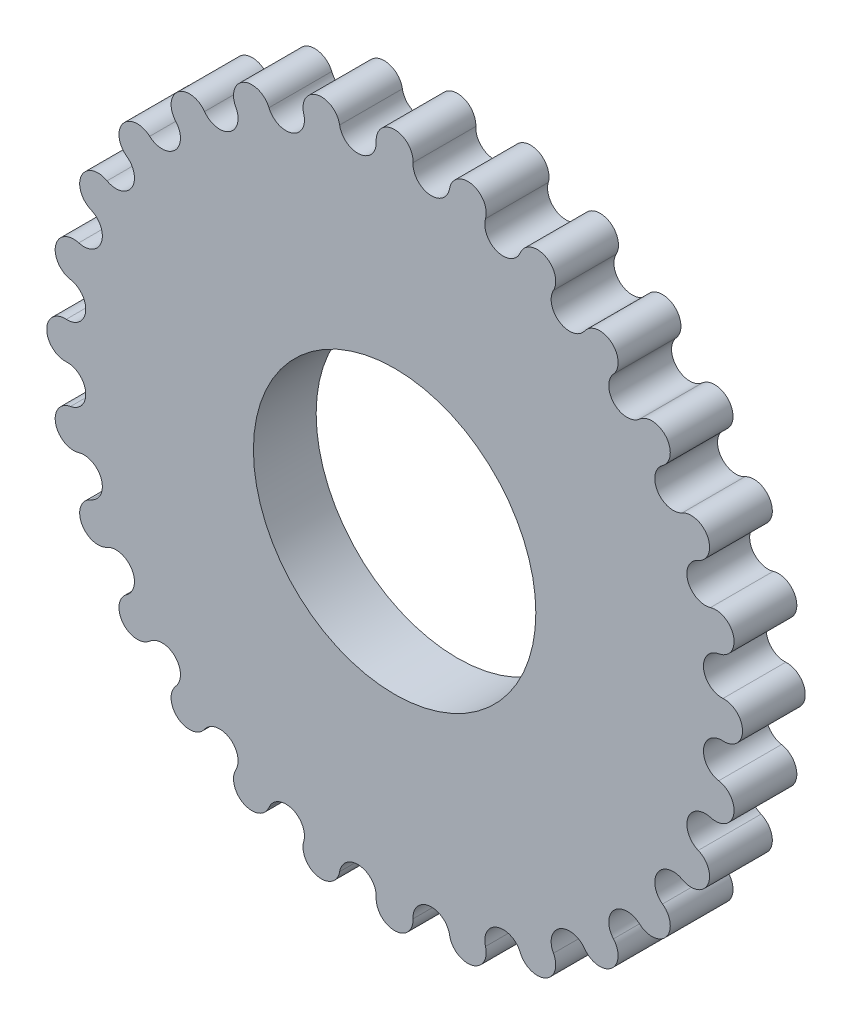
from build123d import *

# Parameters (mm, degrees)
SKETCH1_R           = 9
BOSS_EXTRUDE1_DEPTH = 4


with BuildPart() as part:
    # Sketch1 → Boss-Extrude1 (new body)
    with BuildSketch(Plane.XY):
        with BuildLine():
            ThreePointArc((3.504747833, 20.671687749), (2.214882396, 19.700607102), (1.173151508, 20.934117224))
            ThreePointArc((1.173151508, 20.934117224), (1.173961835, 20.950617719), (1.174540093, 20.967127976))
            ThreePointArc((1.174540093, 20.967127976), (0, 22.175), (-1.174540093, 20.967127976))
            ThreePointArc((-1.174540093, 20.967127976), (-1.173961835, 20.950617719), (-1.173151508, 20.934117224))
            ThreePointArc((-1.173151508, 20.934117224), (-2.214882396, 19.700607102), (-3.504747833, 20.671687749))
            ThreePointArc((-3.504747833, 20.671687749), (-4.924249618, 21.620773739), (-5.792423756, 20.150391748))
            ThreePointArc((-5.792423756, 20.150391748), (-6.534230721, 18.716350991), (-8.007531076, 19.376757329))
            ThreePointArc((-8.007531076, 19.376757329), (-9.602346953, 19.986930953), (-10.122330354, 18.360472593))
            ThreePointArc((-10.122330354, 18.360472593), (-10.527171603, 16.797509372), (-12.110338295, 17.114264311))
            ThreePointArc((-12.110338295, 17.114264311), (-13.800831861, 17.355056827), (-13.94665939, 15.653738554))
            ThreePointArc((-13.94665939, 15.653738554), (-13.994319359, 14.039898725), (-15.608297681, 13.997185253))
            ThreePointArc((-15.608297681, 13.997185253), (-17.310054912, 13.856572796), (-17.074444737, 12.165349162))
            ThreePointArc((-17.074444737, 12.165349162), (-16.762543548, 10.581219081), (-18.32674023, 10.181170075))
            ThreePointArc((-18.32674023, 10.181170075), (-19.954784653, 9.666174064), (-19.349501862, 8.06949555))
            ThreePointArc((-19.349501862, 8.06949555), (-18.693614158, 6.59417803), (-20.129921751, 5.856769754))
            ThreePointArc((-20.129921751, 5.856769754), (-21.602957711, 4.993106281), (-20.658226823, 3.570702301))
            ThreePointArc((-20.658226823, 3.570702301), (-19.691104059, 2.277866648), (-20.927801198, 1.23992125))
            ThreePointArc((-20.927801198, 1.23992125), (-20.94927463, 1.240996152), (-20.970764135, 1.241677968))
            ThreePointArc((-20.970764135, 1.241677968), (-22.172279268, 0.066977177), (-20.970764135, -1.107723614))
            ThreePointArc((-20.970764135, -1.107723614), (-20.94927463, -1.107041799), (-20.927801198, -1.105966896))
            ThreePointArc((-20.927801198, -1.105966896), (-19.691104059, -2.143912295), (-20.658226823, -3.436747947))
            ThreePointArc((-20.658226823, -3.436747947), (-21.602957711, -4.859151928), (-20.129921751, -5.722815401))
            ThreePointArc((-20.129921751, -5.722815401), (-18.693614158, -6.460223676), (-19.349501862, -7.935541197))
            ThreePointArc((-19.349501862, -7.935541197), (-19.954784653, -9.532219711), (-18.32674023, -10.047215721))
            ThreePointArc((-18.32674023, -10.047215721), (-16.762543548, -10.447264727), (-17.074444737, -12.031394809))
            ThreePointArc((-17.074444737, -12.031394809), (-17.310054912, -13.722618442), (-15.608297681, -13.863230899))
            ThreePointArc((-15.608297681, -13.863230899), (-13.994319359, -13.905944371), (-13.94665939, -15.5197842))
            ThreePointArc((-13.94665939, -15.5197842), (-13.800831861, -17.221102473), (-12.110338295, -16.980309958))
            ThreePointArc((-12.110338295, -16.980309958), (-10.527171603, -16.663555018), (-10.122330354, -18.226518239))
            ThreePointArc((-10.122330354, -18.226518239), (-9.602346953, -19.852976599), (-8.007531076, -19.242802976))
            ThreePointArc((-8.007531076, -19.242802976), (-6.534230721, -18.582396638), (-5.792423756, -20.016437395))
            ThreePointArc((-5.792423756, -20.016437395), (-4.924249618, -21.486819385), (-3.504747833, -20.537733396))
            ThreePointArc((-3.504747833, -20.537733396), (-2.214882396, -19.566652749), (-1.173151508, -20.800162871))
            ThreePointArc((-1.173151508, -20.800162871), (-1.173961835, -20.816663366), (-1.174540093, -20.833173623))
            ThreePointArc((-1.174540093, -20.833173623), (0, -22.041045646), (1.174540093, -20.833173623))
            ThreePointArc((1.174540093, -20.833173623), (1.173961835, -20.816663366), (1.173151508, -20.800162871))
            ThreePointArc((1.173151508, -20.800162871), (2.214882396, -19.566652749), (3.504747833, -20.537733396))
            ThreePointArc((3.504747833, -20.537733396), (4.924249618, -21.486819385), (5.792423756, -20.016437395))
            ThreePointArc((5.792423756, -20.016437395), (6.534230721, -18.582396638), (8.007531076, -19.242802976))
            ThreePointArc((8.007531076, -19.242802976), (9.602346953, -19.852976599), (10.122330354, -18.226518239))
            ThreePointArc((10.122330354, -18.226518239), (10.527171603, -16.663555018), (12.110338295, -16.980309958))
            ThreePointArc((12.110338295, -16.980309958), (13.800831861, -17.221102473), (13.94665939, -15.5197842))
            ThreePointArc((13.94665939, -15.5197842), (13.994319359, -13.905944371), (15.608297681, -13.863230899))
            ThreePointArc((15.608297681, -13.863230899), (17.310054912, -13.722618442), (17.074444737, -12.031394809))
            ThreePointArc((17.074444737, -12.031394809), (16.762543548, -10.447264727), (18.32674023, -10.047215721))
            ThreePointArc((18.32674023, -10.047215721), (19.954784653, -9.532219711), (19.349501862, -7.935541197))
            ThreePointArc((19.349501862, -7.935541197), (18.693614158, -6.460223676), (20.129921751, -5.722815401))
            ThreePointArc((20.129921751, -5.722815401), (21.602957711, -4.859151928), (20.658226823, -3.436747947))
            ThreePointArc((20.658226823, -3.436747947), (19.691104059, -2.143912295), (20.927801198, -1.105966896))
            ThreePointArc((20.927801198, -1.105966896), (20.94927463, -1.107041799), (20.970764135, -1.107723614))
            ThreePointArc((20.970764135, -1.107723614), (22.172279268, 0.066977177), (20.970764135, 1.241677968))
            ThreePointArc((20.970764135, 1.241677968), (20.94927463, 1.240996152), (20.927801198, 1.23992125))
            ThreePointArc((20.927801198, 1.23992125), (19.691104059, 2.277866648), (20.658226823, 3.570702301))
            ThreePointArc((20.658226823, 3.570702301), (21.602957711, 4.993106281), (20.129921751, 5.856769754))
            ThreePointArc((20.129921751, 5.856769754), (18.693614158, 6.59417803), (19.349501862, 8.06949555))
            ThreePointArc((19.349501862, 8.06949555), (19.954784653, 9.666174064), (18.32674023, 10.181170075))
            ThreePointArc((18.32674023, 10.181170075), (16.762543548, 10.581219081), (17.074444737, 12.165349162))
            ThreePointArc((17.074444737, 12.165349162), (17.310054912, 13.856572796), (15.608297681, 13.997185253))
            ThreePointArc((15.608297681, 13.997185253), (13.994319359, 14.039898725), (13.94665939, 15.653738554))
            ThreePointArc((13.94665939, 15.653738554), (13.800831861, 17.355056827), (12.110338295, 17.114264311))
            ThreePointArc((12.110338295, 17.114264311), (10.527171603, 16.797509372), (10.122330354, 18.360472593))
            ThreePointArc((10.122330354, 18.360472593), (9.602346953, 19.986930953), (8.007531076, 19.376757329))
            ThreePointArc((8.007531076, 19.376757329), (6.534230721, 18.716350991), (5.792423756, 20.150391748))
            ThreePointArc((5.792423756, 20.150391748), (4.924249618, 21.620773739), (3.504747833, 20.671687749))
        make_face()
        Circle(SKETCH1_R, mode=Mode.SUBTRACT)
    extrude(amount=BOSS_EXTRUDE1_DEPTH)


solid = part.part
